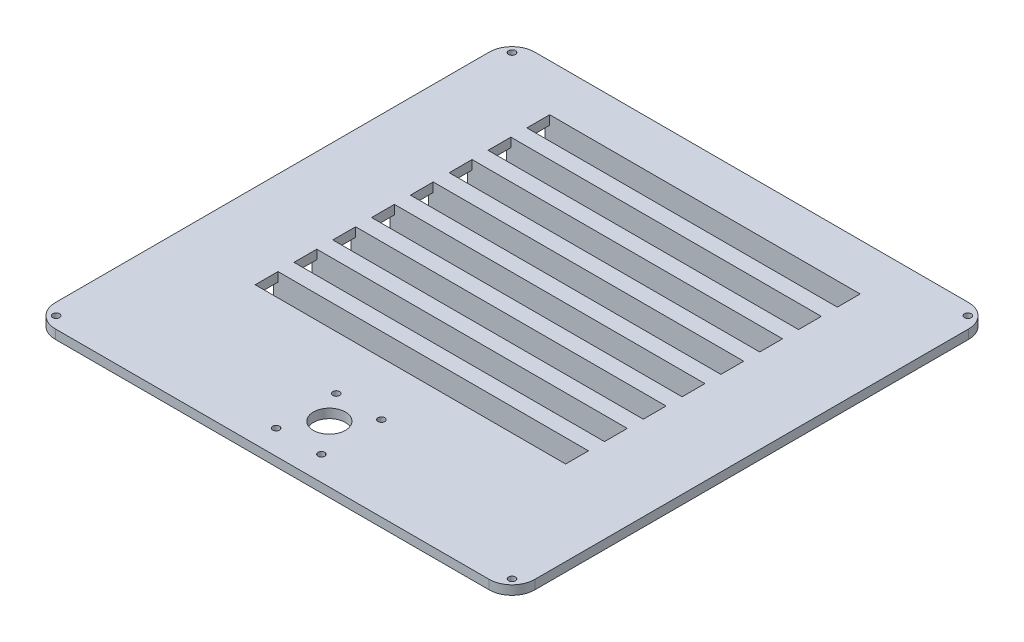
from build123d import *

# Parameters (mm, degrees)
SKETCH1_W               = 210
SKETCH1_H               = 210
MAINEXTRUDE_DEPTH       = 4
SKETCH1_6_R             = 1.5
SCREWHOLES_DEPTH        = 4
ROUNDEDCORNERS_R        = 10
SKETCH3_R               = 7
SKETCH3_R_2             = 1.5
SKETCH3_W               = 136
SKETCH3_H               = 10
TRENCH_DEPTH            = 10
SKETCH4_W               = 140
SKETCH4_H               = 14
SKETCH4_W_2             = 136
SKETCH4_H_2             = 10
TRENCH_WALLS_DEPTH      = 4
SKETCH5_W               = 140
SKETCH5_H               = 14
TRENCH_BOTTOM_DEPTH     = 2
SKETCH7_W               = 10
SKETCH7_H               = 6
WIRE_OPENING_DEPTH      = 36
WIRE_OPENING_DEPTH_BACK = 176
SKETCH9_R               = 2
SKETCH9_R_2             = 0.98
PCB_HOLES_DEPTH         = 4
PCB_ROUNDS_R            = 2


with BuildPart() as part:
    # Sketch1 → MainExtrude (new body)
    with BuildSketch(Plane(origin=(0, 0, 0), x_dir=(1, 0, 0), z_dir=(0, 1, 0))):
        Rectangle(SKETCH1_W, SKETCH1_H)
    extrude(amount=MAINEXTRUDE_DEPTH)

    # Sketch1_6 → ScrewHoles (cut)
    with BuildSketch(Plane(origin=(0, 0, 0), x_dir=(1, 0, 0), z_dir=(0, 1, 0))):
        with Locations((-99.833273811, 99.833273811)):
            Circle(SKETCH1_6_R)
        with Locations((-99.833273811, -99.833273811)):
            Circle(SKETCH1_6_R)
        with Locations((99.833273811, -99.833273811)):
            Circle(SKETCH1_6_R)
        with Locations((99.833273811, 99.833273811)):
            Circle(SKETCH1_6_R)
    extrude(amount=SCREWHOLES_DEPTH, mode=Mode.SUBTRACT)

    # RoundedCorners
    roundedcorners_edges = [part.edges().sort_by_distance(p)[0] for p in [
        (-105, 2, -105),
        (-105, 2, 105),
        (105, 2, 105),
        (105, 2, -105),
    ]]
    fillet(roundedcorners_edges, radius=ROUNDEDCORNERS_R)

    # Sketch3 → Trench (cut)
    with BuildSketch(Plane(origin=(0, 0, 0), x_dir=(1, 0, 0), z_dir=(0, 1, 0))):
        with Locations((0, -80)):
            Circle(SKETCH3_R)
        with Locations((-9, -68)):
            Circle(SKETCH3_R_2)
        with Locations((-9, -94.3)):
            Circle(SKETCH3_R_2)
        with Locations((10.8, -94.3)):
            Circle(SKETCH3_R_2)
        with Locations((10.8, -68)):
            Circle(SKETCH3_R_2)
        with Locations((0, 79.5)):
            Rectangle(SKETCH3_W, SKETCH3_H)
        with Locations((0, 62.5)):
            Rectangle(SKETCH3_W, SKETCH3_H)
        with Locations((0, 45.5)):
            Rectangle(SKETCH3_W, SKETCH3_H)
        with Locations((0, 28.5)):
            Rectangle(SKETCH3_W, SKETCH3_H)
        with Locations((0, 11.5)):
            Rectangle(SKETCH3_W, SKETCH3_H)
        with Locations((0, -5.5)):
            Rectangle(SKETCH3_W, SKETCH3_H)
        with Locations((0, -22.5)):
            Rectangle(SKETCH3_W, SKETCH3_H)
        with Locations((0, -39.5)):
            Rectangle(SKETCH3_W, SKETCH3_H)
    extrude(amount=TRENCH_DEPTH, mode=Mode.SUBTRACT)

    # Sketch4 → Trench Walls (add)
    with BuildSketch(Plane(origin=(0, 0, 0), x_dir=(1, 0, 0), z_dir=(0, 1, 0))):
        with Locations((0, 79.5)):
            Rectangle(SKETCH4_W, SKETCH4_H)
        with Locations((0, 79.5)):
            Rectangle(SKETCH4_W_2, SKETCH4_H_2, mode=Mode.SUBTRACT)
        with Locations((0, 62.5)):
            Rectangle(SKETCH4_W, SKETCH4_H)
        with Locations((0, 62.5)):
            Rectangle(SKETCH4_W_2, SKETCH4_H_2, mode=Mode.SUBTRACT)
        with Locations((0, 45.5)):
            Rectangle(SKETCH4_W, SKETCH4_H)
        with Locations((0, 45.5)):
            Rectangle(SKETCH4_W_2, SKETCH4_H_2, mode=Mode.SUBTRACT)
        with Locations((0, 28.5)):
            Rectangle(SKETCH4_W, SKETCH4_H)
        with Locations((0, 28.5)):
            Rectangle(SKETCH4_W_2, SKETCH4_H_2, mode=Mode.SUBTRACT)
        with Locations((0, 11.5)):
            Rectangle(SKETCH4_W, SKETCH4_H)
        with Locations((0, 11.5)):
            Rectangle(SKETCH4_W_2, SKETCH4_H_2, mode=Mode.SUBTRACT)
        with Locations((0, -5.5)):
            Rectangle(SKETCH4_W, SKETCH4_H)
        with Locations((0, -5.5)):
            Rectangle(SKETCH4_W_2, SKETCH4_H_2, mode=Mode.SUBTRACT)
        with Locations((0, -22.5)):
            Rectangle(SKETCH4_W, SKETCH4_H)
        with Locations((0, -22.5)):
            Rectangle(SKETCH4_W_2, SKETCH4_H_2, mode=Mode.SUBTRACT)
        with Locations((0, -39.5)):
            Rectangle(SKETCH4_W, SKETCH4_H)
        with Locations((0, -39.5)):
            Rectangle(SKETCH4_W_2, SKETCH4_H_2, mode=Mode.SUBTRACT)
    extrude(amount=-TRENCH_WALLS_DEPTH)

    # Sketch5 → Trench Bottom (add)
    with BuildSketch(Plane.XZ.offset(4)):
        with Locations((0, -79.5)):
            Rectangle(SKETCH5_W, SKETCH5_H)
        with Locations((0, -62.5)):
            Rectangle(SKETCH5_W, SKETCH5_H)
        with Locations((0, -45.5)):
            Rectangle(SKETCH5_W, SKETCH5_H)
        with Locations((0, -28.5)):
            Rectangle(SKETCH5_W, SKETCH5_H)
        with Locations((0, -11.5)):
            Rectangle(SKETCH5_W, SKETCH5_H)
        with Locations((0, 5.5)):
            Rectangle(SKETCH5_W, SKETCH5_H)
        with Locations((0, 22.5)):
            Rectangle(SKETCH5_W, SKETCH5_H)
        with Locations((0, 39.5)):
            Rectangle(SKETCH5_W, SKETCH5_H)
    extrude(amount=TRENCH_BOTTOM_DEPTH)

    # Sketch7 → Wire Opening (cut, two sides)
    with BuildSketch(Plane(origin=(70, 0, 0), x_dir=(0, 0, -1), z_dir=(1, 0, 0))) as wire_opening_sk:
        with Locations((-39.5, -3)):
            Rectangle(SKETCH7_W, SKETCH7_H)
        with Locations((-22.5, -3)):
            Rectangle(SKETCH7_W, SKETCH7_H)
        with Locations((-5.5, -3)):
            Rectangle(SKETCH7_W, SKETCH7_H)
        with Locations((11.5, -3)):
            Rectangle(SKETCH7_W, SKETCH7_H)
        with Locations((28.5, -3)):
            Rectangle(SKETCH7_W, SKETCH7_H)
        with Locations((45.5, -3)):
            Rectangle(SKETCH7_W, SKETCH7_H)
        with Locations((62.5, -3)):
            Rectangle(SKETCH7_W, SKETCH7_H)
        with Locations((79.5, -3)):
            Rectangle(SKETCH7_W, SKETCH7_H)
    extrude(amount=WIRE_OPENING_DEPTH, mode=Mode.SUBTRACT)
    extrude(wire_opening_sk.sketch, amount=-WIRE_OPENING_DEPTH_BACK, mode=Mode.SUBTRACT)

    # Sketch9 → PCB Holes (add)
    with BuildSketch(Plane.XZ):
        with Locations((-94, 92)):
            Circle(SKETCH9_R)
        with Locations((-94, 92)):
            Circle(SKETCH9_R_2, mode=Mode.SUBTRACT)
        with Locations((-19.73, 92)):
            Circle(SKETCH9_R)
        with Locations((-19.73, 92)):
            Circle(SKETCH9_R_2, mode=Mode.SUBTRACT)
        with Locations((-94, 56.16)):
            Circle(SKETCH9_R)
        with Locations((-94, 56.16)):
            Circle(SKETCH9_R_2, mode=Mode.SUBTRACT)
        with Locations((-19.73, 56.16)):
            Circle(SKETCH9_R)
        with Locations((-19.73, 56.16)):
            Circle(SKETCH9_R_2, mode=Mode.SUBTRACT)
    extrude(amount=PCB_HOLES_DEPTH)

    # PCB Rounds
    pcb_rounds_edges = [part.edges().sort_by_distance(p)[0] for p in [
        (-96, 0, 92),
        (-21.73, 0, 56.16),
        (-96, 0, 56.16),
        (-21.73, 0, 92),
    ]]
    fillet(pcb_rounds_edges, radius=PCB_ROUNDS_R)


solid = part.part
